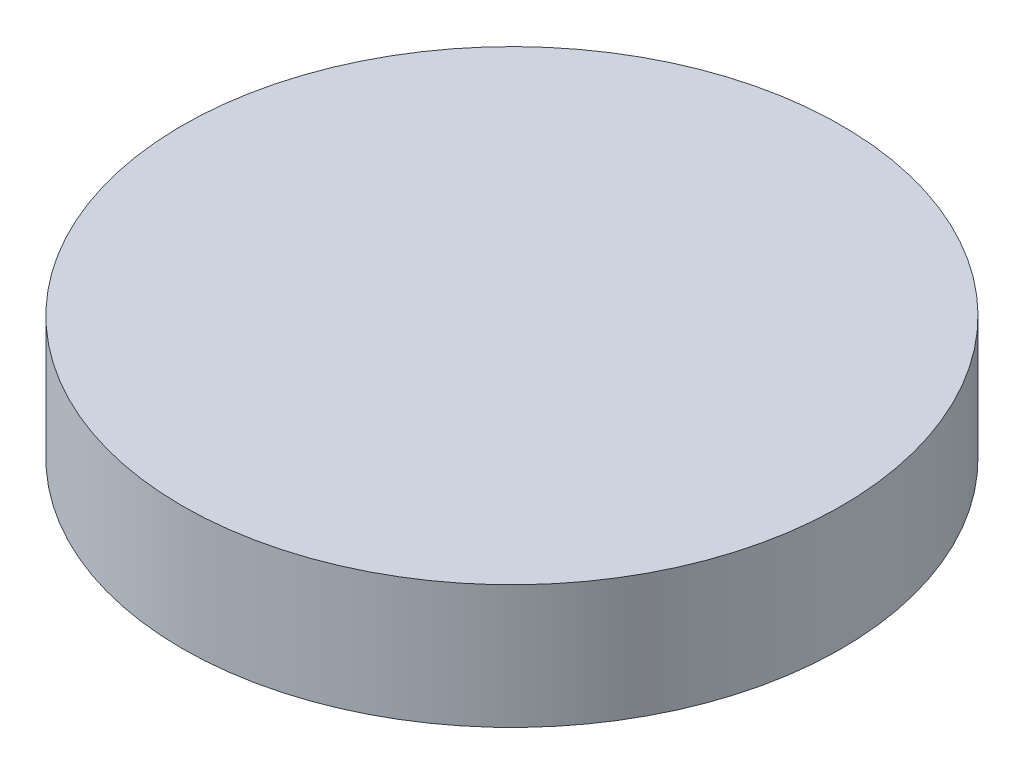
from build123d import *

# Parameters (mm, degrees)
SKETCH_1_R      = 101.6
EXTRUDE_1_DEPTH = 38.1


with BuildPart() as part:
    # 草图1 → 凸台-拉伸1 (new body)
    with BuildSketch(Plane(origin=(0, 0, 0), x_dir=(1, 0, 0), z_dir=(0, 1, 0))):
        with Locations(Location((0, 0, 0), (0, 0, 270))):  # turned: the seam where the file's is
            Circle(SKETCH_1_R)
    extrude(amount=EXTRUDE_1_DEPTH)


solid = part.part
